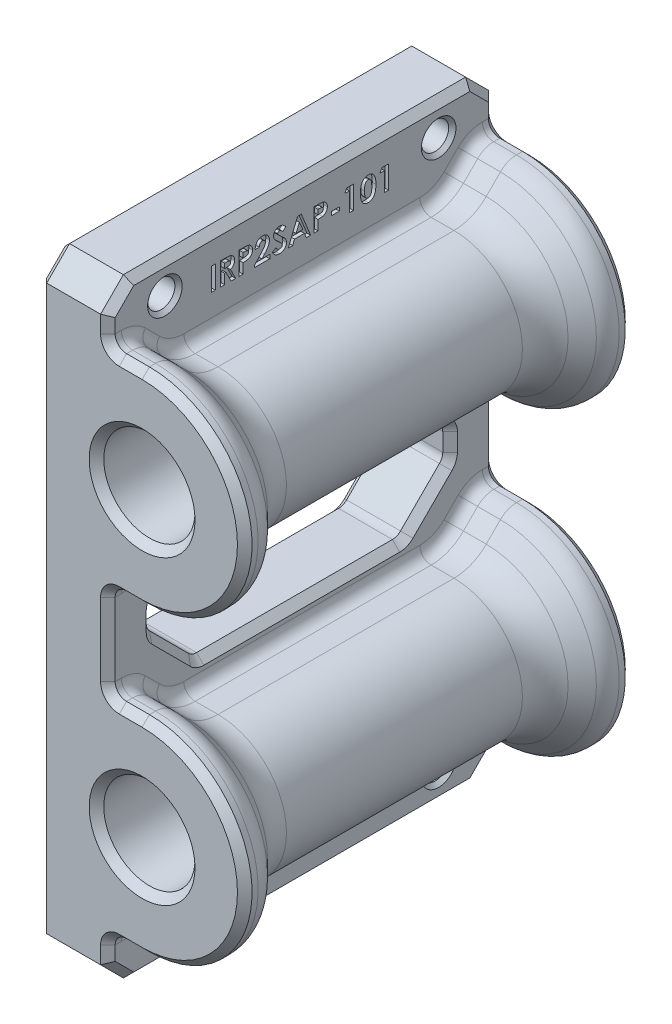
from build123d import *

# Parameters (mm, degrees)
SKETCH1_R             = 6.35
BOSS_EXTRUDE1_DEPTH   = 53.975
CUT_REVOLVE1_ANGLE    = 180
CUT_EXTRUDE3_DEPTH    = 4.7625
FILLET2_R             = 6.35
FILLET3_R             = 3.175
F_6_CLEARANCE_HOLE1_D = 3.7973
CUT_EXTRUDE1_DEPTH    = 10.525
FILLET1_R             = 1.5875
CHAMFER2_SIZE         = 3.175
CHAMFER1_SIZE         = 1.016
CHAMFER3_SIZE         = 0.508
SKETCH7_W             = 0.569871794
SKETCH7_H             = 3.175
SKETCH7_W_2           = 1.099038461
SKETCH7_H_2           = 0.529166666
CUT_EXTRUDE2_DEPTH    = 0.508


with BuildPart() as part:
    # Sketch1 → Boss-Extrude1 (new body)
    with BuildSketch(Plane.XY):
        with BuildLine():
            Line((0, 0), (0, -84.7725))
            Line((0, -84.7725), (14.2875, -84.7725))
            Line((14.2875, -84.7725), (14.2875, -77.62875))
            ThreePointArc((14.2875, -77.62875), (28.575, -63.34125), (14.2875, -49.05375))
            Line((14.2875, -49.05375), (14.2875, -35.71875))
            ThreePointArc((14.2875, -35.71875), (28.575, -21.43125), (14.2875, -7.14375))
            Line((14.2875, -7.14375), (14.2875, 0))
            Line((14.2875, 0), (0, 0))
        make_face()
        with Locations((14.2875, -21.43125)):
            Circle(SKETCH1_R, mode=Mode.SUBTRACT)
        with Locations((14.2875, -63.34125)):
            Circle(SKETCH1_R, mode=Mode.SUBTRACT)
    extrude(amount=BOSS_EXTRUDE1_DEPTH)

    # Sketch8 → Cut-Revolve1 (revolve, cut)
    with BuildSketch(Plane(origin=(14.2875, 0, 0), x_dir=(0, 0, -1), z_dir=(1, 0, 0))):
        Polygon((-46.0375, -30.95625), (-50.8, -35.71875), (-3.175, -35.71875), (-7.9375, -30.95625), align=None)
    cut_revolve1 = revolve(axis=Axis((14.2875, -21.43125, 53.975), (0, 0, 1)), revolution_arc=CUT_REVOLVE1_ANGLE, mode=Mode.SUBTRACT)

    # Mirror1: Cut-Revolve1 across plane
    add(cut_revolve1.mirror(Plane(origin=(0, -42.38625, 0), x_dir=(0, 0, 1), z_dir=(0, -1, 0))), mode=Mode.SUBTRACT)

    # Sketch9 → Cut-Extrude3 (cut)
    with BuildSketch(Plane(origin=(14.2875, 0, 0), x_dir=(0, 0, -1), z_dir=(1, 0, 0))):
        Polygon((0, -7.14375), (0, 0), (-53.975, 0), (-53.975, -7.14375), (-50.8, -7.14375), (-46.0375, -11.90625), (-7.9375, -11.90625), (-3.175, -7.14375), align=None)
        Polygon((0, -49.05375), (0, -35.71875), (-3.175, -35.71875), (-7.9375, -30.95625), (-46.0375, -30.95625), (-50.8, -35.71875), (-53.975, -35.71875), (-53.975, -49.05375), (-50.8, -49.05375), (-46.0375, -53.81625), (-7.9375, -53.81625), (-3.175, -49.05375), align=None)
        Polygon((0, -84.7725), (0, -77.62875), (-3.175, -77.62875), (-7.9375, -72.86625), (-46.0375, -72.86625), (-50.8, -77.62875), (-53.975, -77.62875), (-53.975, -84.7725), align=None)
    extrude(amount=-CUT_EXTRUDE3_DEPTH, mode=Mode.SUBTRACT)

    # Fillet2
    fillet2_edges = [part.edges().sort_by_distance(p)[0] for p in [
        (23.8125, -21.43125, 7.9375),
        (23.8125, -21.43125, 46.0375),
        (23.8125, -63.34125, 7.9375),
        (23.8125, -63.34125, 46.0375),
        (11.90625, -11.90625, 7.9375),
        (11.90625, -11.90625, 46.0375),
        (11.90625, -53.81625, 7.9375),
        (11.90625, -53.81625, 46.0375),
        (11.90625, -30.95625, 46.0375),
        (11.90625, -30.95625, 7.9375),
        (11.90625, -72.86625, 46.0375),
        (11.90625, -72.86625, 7.9375),
    ]]
    fillet(fillet2_edges, radius=FILLET2_R)

    # Fillet3
    fillet3_edges = [part.edges().sort_by_distance(p)[0] for p in [
        (28.575, -21.43125, 3.175),
        (28.575, -21.43125, 50.8),
        (28.575, -63.34125, 50.8),
        (28.575, -63.34125, 3.175),
        (11.90625, -7.14375, 3.175),
        (11.90625, -7.14375, 50.8),
        (11.90625, -49.05375, 3.175),
        (11.90625, -49.05375, 50.8),
        (11.90625, -35.71875, 50.8),
        (11.90625, -35.71875, 3.175),
        (11.90625, -77.62875, 50.8),
        (11.90625, -77.62875, 3.175),
    ]]
    fillet(fillet3_edges, radius=FILLET3_R)

    # #6 Clearance Hole1 (through all)
    with Locations(Plane(origin=(9.525, 0, 0), x_dir=(0, 0, -1), z_dir=(1, 0, 0))):
        with Locations((-46.0375, -4.445), (-7.9375, -4.445), (-46.0375, -80.3275), (-7.9375, -80.3275)):
            Hole(F_6_CLEARANCE_HOLE1_D / 2)

    # Sketch6 → Cut-Extrude1 (cut, through all)
    with BuildSketch(Plane(origin=(9.525, 0, 0), x_dir=(0, 0, -1), z_dir=(1, 0, 0))):
        Polygon((-41.275, -34.13125), (-47.625, -40.48125), (-47.625, -44.29125), (-41.275, -50.64125), (-12.7, -50.64125), (-6.35, -44.29125), (-6.35, -40.48125), (-12.7, -34.13125), align=None)
    extrude(amount=-CUT_EXTRUDE1_DEPTH, mode=Mode.SUBTRACT)

    # Fillet1
    fillet1_edges = [part.edges().sort_by_distance(p)[0] for p in [
        (9.525, -11.90625, 26.9875),
        (9.525, -9.060032015, 48.883717985),
        (9.525, -11.422885031, 45.837283674),
        (9.525, -11.422885031, 8.137716326),
        (9.525, -30.95625, 26.9875),
        (9.525, -33.802467985, 5.091282015),
        (9.525, -50.970032015, 48.883717985),
        (9.525, -53.81625, 26.9875),
        (9.525, -53.332885031, 45.837283674),
        (9.525, -53.332885031, 8.137716326),
        (9.525, -31.439614969, 45.837283674),
        (9.525, -31.439614969, 8.137716326),
        (9.525, -72.86625, 26.9875),
        (9.525, -75.712467985, 5.091282015),
        (9.525, -73.349614969, 45.837283674),
        (9.525, -73.349614969, 8.137716326),
        (9.525, -9.060032015, 5.091282015),
        (9.525, -35.71875, 0.92993597),
        (9.525, -7.14375, 53.04506403),
        (9.525, -33.802467985, 48.883717985),
        (9.525, -77.62875, 0.92993597),
        (9.525, -50.970032015, 5.091282015),
        (9.525, -75.712467985, 48.883717985),
        (9.525, -49.05375, 53.04506403),
        (9.525, -7.385432484, 3.074891837),
        (9.525, -35.477067516, 3.074891837),
        (9.525, -7.385432484, 50.900108163),
        (9.525, -35.477067516, 50.900108163),
        (9.525, -77.387067516, 3.074891837),
        (9.525, -49.295432484, 3.074891837),
        (9.525, -77.387067516, 50.900108163),
        (9.525, -49.295432484, 50.900108163),
        (4.7625, -34.13125, 41.275),
        (4.7625, -34.13125, 12.7),
        (4.7625, -40.48125, 6.35),
        (4.7625, -44.29125, 6.35),
        (4.7625, -50.64125, 12.7),
        (4.7625, -50.64125, 41.275),
        (4.7625, -44.29125, 47.625),
        (4.7625, -40.48125, 47.625),
        (9.525, -7.14375, 0.92993597),
        (9.525, -49.05375, 0.92993597),
        (9.525, -35.71875, 53.04506403),
        (9.525, -77.62875, 53.04506403),
    ]]
    fillet(fillet1_edges, radius=FILLET1_R)

    # Chamfer2
    chamfer2_edges = [part.edges().sort_by_distance(p)[0] for p in [
        (4.7625, -84.7725, 0),
        (4.7625, -84.7725, 53.975),
        (4.7625, 0, 0),
        (4.7625, 0, 53.975),
    ]]
    chamfer(chamfer2_edges, length=CHAMFER2_SIZE)

    # Chamfer1
    chamfer1_edges = [part.edges().sort_by_distance(p)[0] for p in [
        (28.575, -63.34125, 53.975),
        (7.9375, -21.43125, 0),
        (7.9375, -21.43125, 53.975),
        (7.9375, -63.34125, 0),
        (7.9375, -63.34125, 53.975),
        (28.575, -21.43125, 53.975),
        (12.7, -35.71875, 53.975),
        (9.525, -34.13125, 26.9875),
        (9.525, -37.30625, 9.525),
        (9.525, -42.38625, 6.35),
        (9.525, -47.46625, 9.525),
        (9.525, -50.64125, 26.9875),
        (9.525, -47.46625, 44.45),
        (9.525, -42.38625, 47.625),
        (9.525, -37.30625, 44.45),
        (9.525, -42.38625, 53.975),
        (9.525, -42.38625, 0),
        (12.7, -35.71875, 0),
        (12.7, -7.14375, 0),
        (9.525, -4.365625, 53.975),
        (12.7, -7.14375, 53.975),
        (12.7, -49.05375, 0),
        (12.7, -49.05375, 53.975),
        (12.7, -77.62875, 53.975),
        (9.525, -80.406875, 0),
        (12.7, -77.62875, 0),
        (0, -47.46625, 9.525),
        (0, -50.64125, 26.9875),
        (0, -47.46625, 44.45),
        (0, -42.38625, 47.625),
        (0, -37.30625, 44.45),
        (0, -34.13125, 26.9875),
        (0, -42.38625, 6.35),
        (0, -37.30625, 9.525),
        (9.989967985, -36.183717985, 53.975),
        (9.989967985, -36.183717985, 0),
        (9.989967985, -6.678782015, 0),
        (9.989967985, -6.678782015, 53.975),
        (9.989967985, -48.588782015, 0),
        (9.989967985, -48.588782015, 53.975),
        (9.989967985, -78.093717985, 53.975),
        (9.989967985, -78.093717985, 0),
        (9.525, -50.520408758, 12.750054081),
        (0, -50.520408758, 12.750054081),
        (9.525, -50.520408758, 41.224945919),
        (0, -50.520408758, 41.224945919),
        (9.525, -44.241195919, 47.504158758),
        (0, -44.241195919, 47.504158758),
        (9.525, -40.531304081, 47.504158758),
        (0, -40.531304081, 47.504158758),
        (9.525, -34.252091242, 41.224945919),
        (0, -34.252091242, 41.224945919),
        (9.525, -44.241195919, 6.470841242),
        (0, -44.241195919, 6.470841242),
        (9.525, -40.531304081, 6.470841242),
        (0, -40.531304081, 6.470841242),
        (9.525, -34.252091242, 12.750054081),
        (0, -34.252091242, 12.750054081),
        (9.525, -84.7725, 26.9875),
        (0, -84.7725, 26.9875),
        (9.525, -80.406875, 53.975),
        (9.525, -83.185, 52.3875),
        (9.525, -83.185, 1.5875),
        (9.525, -4.365625, 0),
        (0, -42.38625, 0),
        (0, -42.38625, 53.975),
        (0, 0, 26.9875),
        (0, -1.5875, 52.3875),
        (0, -1.5875, 1.5875),
        (0, -83.185, 52.3875),
        (0, -83.185, 1.5875),
        (9.525, 0, 26.9875),
        (9.525, -1.5875, 52.3875),
        (9.525, -1.5875, 1.5875),
        (28.575, -21.43125, 0),
        (28.575, -63.34125, 0),
    ]]
    chamfer(chamfer1_edges, length=CHAMFER1_SIZE)

    # Chamfer3
    chamfer3_edges = [part.edges().sort_by_distance(p)[0] for p in [
        (9.525, -80.3275, 6.03885),
        (0, -80.3275, 6.03885),
        (9.525, -80.3275, 44.13885),
        (0, -80.3275, 44.13885),
        (9.525, -4.445, 6.03885),
        (0, -4.445, 6.03885),
        (9.525, -4.445, 44.13885),
        (0, -4.445, 44.13885),
    ]]
    chamfer(chamfer3_edges, length=CHAMFER3_SIZE)

    # Sketch7 → Cut-Extrude2 (cut)
    with BuildSketch(Plane(origin=(9.525, 0, 0), x_dir=(0, 0, -1), z_dir=(1, 0, 0))):
        with Locations((-39.300801282, -5.667375)):
            Rectangle(SKETCH7_W, SKETCH7_H)
        with BuildLine():
            Line((-38.283173077, -4.079875), (-37.619170673, -4.079875))
            add(Edge.make_bspline(
                [(-37.619170673, -4.079875), (-37.575280316, -4.080030786), (-37.490866797, -4.080330405), (-37.369147113, -4.085057608), (-37.257330843, -4.091635899), (-37.155252435, -4.101674545), (-37.062955559, -4.114984576), (-36.980347711, -4.130674901), (-36.907431307, -4.14855739), (-36.843591397, -4.170840381), (-36.785979034, -4.195975258), (-36.732276303, -4.224855693), (-36.681298441, -4.257160092), (-36.633386179, -4.293738472), (-36.58812315, -4.333932798), (-36.545423961, -4.377783527), (-36.505891992, -4.425662498), (-36.469772026, -4.477267174), (-36.436851584, -4.53155411), (-36.407756819, -4.588597843), (-36.384096907, -4.648438041), (-36.363190839, -4.710209886), (-36.348132875, -4.774796417), (-36.337660281, -4.841568875), (-36.329992658, -4.910762304), (-36.329551806, -4.957769247), (-36.329326923, -4.981747997)],
                knots=[0, 0, 0, 0, 0.000131662, 0.000253223, 0.00036538, 0.000467651, 0.000560835, 0.000645033, 0.000719848, 0.000785822, 0.000847624, 0.000908233, 0.000968574, 0.001028488, 0.00108886, 0.00115003, 0.00121192, 0.001274915, 0.001338834, 0.001402263, 0.001466749, 0.001531714, 0.00159774, 0.001665392, 0.001734437, 0.001806332, 0.001806332, 0.001806332, 0.001806332], degree=3))
            add(Edge.make_bspline(
                [(-36.329326923, -4.981747997), (-36.329911089, -5.006776303), (-36.331056531, -5.055852249), (-36.337226507, -5.127940812), (-36.348503286, -5.196910106), (-36.365583607, -5.262558199), (-36.385215218, -5.325702157), (-36.411320224, -5.385176934), (-36.440782304, -5.441847505), (-36.475773556, -5.494912244), (-36.514174745, -5.545549824), (-36.55883452, -5.591820132), (-36.606859614, -5.636210022), (-36.660949691, -5.675939061), (-36.718720412, -5.713693583), (-36.78131962, -5.747909235), (-36.84833877, -5.779446119), (-36.895456552, -5.797033263), (-36.919551282, -5.806026843)],
                knots=[0, 0, 0, 0, 7.5093e-05, 0.000147244, 0.000216881, 0.000284446, 0.00035062, 0.000415008, 0.000479022, 0.000542001, 0.000605481, 0.000669369, 0.000734656, 0.000801438, 0.000870416, 0.000941581, 0.001015277, 0.001092403, 0.001092403, 0.001092403, 0.001092403], degree=3))
            Line((-36.919551282, -5.806026843), (-36.186858974, -7.254875))
            Line((-36.186858974, -7.254875), (-36.820332532, -7.254875))
            Line((-36.820332532, -7.254875), (-37.519951923, -5.870900641))
            Line((-37.519951923, -5.870900641), (-37.713301282, -5.870900641))
            Line((-37.713301282, -5.870900641), (-37.713301282, -7.254875))
            Line((-37.713301282, -7.254875), (-38.283173077, -7.254875))
            Line((-38.283173077, -7.254875), (-38.283173077, -4.079875))
        make_face()
        with BuildLine():
            Line((-37.713301282, -5.301028846), (-37.49133113, -5.301028846))
            add(Edge.make_bspline(
                [(-37.49133113, -5.301028846), (-37.464193434, -5.300723203), (-37.412230576, -5.300137963), (-37.337501163, -5.297423374), (-37.269629034, -5.290882557), (-37.208322722, -5.282618479), (-37.153273742, -5.273076407), (-37.104973109, -5.25940204), (-37.062676585, -5.244749608), (-37.026885385, -5.226540437), (-36.996306206, -5.20583266), (-36.969903042, -5.182308111), (-36.94806384, -5.15508144), (-36.930089063, -5.124892552), (-36.916106641, -5.091474433), (-36.905900543, -5.055193938), (-36.900196844, -5.015637786), (-36.899540614, -4.988338655), (-36.899198718, -4.974115785)],
                knots=[0, 0, 0, 0, 8.142e-05, 0.000155902, 0.000224253, 0.000285868, 0.000341504, 0.000391652, 0.000436319, 0.000475572, 0.000511736, 0.000546861, 0.000581229, 0.000616025, 0.000651936, 0.00068959, 0.000728807, 0.000771463, 0.000771463, 0.000771463, 0.000771463], degree=3))
            add(Edge.make_bspline(
                [(-36.899198718, -4.974115785), (-36.899845104, -4.957289092), (-36.901114811, -4.92423617), (-36.913714243, -4.876651553), (-36.933769817, -4.832608734), (-36.961260515, -4.79230671), (-36.995881476, -4.756975173), (-37.035611761, -4.725830142), (-37.081308844, -4.701202982), (-37.123620904, -4.68495917), (-37.162114988, -4.675240329), (-37.196854685, -4.667997935), (-37.237083463, -4.662865042), (-37.282831693, -4.657420696), (-37.333982761, -4.653890313), (-37.390815471, -4.651313837), (-37.4531666, -4.650259674), (-37.496631258, -4.649922677), (-37.519315905, -4.649746795)],
                knots=[0, 0, 0, 0, 5.039e-05, 9.8982e-05, 0.000146513, 0.000195026, 0.000244505, 0.000294375, 0.000345896, 0.000399642, 0.000429878, 0.000464928, 0.000506034, 0.000551477, 0.000603136, 0.000659798, 0.000722141, 0.000790198, 0.000790198, 0.000790198, 0.000790198], degree=3))
            Line((-37.519315905, -4.649746795), (-37.713301282, -4.649746795))
            Line((-37.713301282, -4.649746795), (-37.713301282, -5.301028846))
        make_face(mode=Mode.SUBTRACT)
        with BuildLine():
            Line((-35.71875, -4.079875), (-35.082732372, -4.079875))
            add(Edge.make_bspline(
                [(-35.082732372, -4.079875), (-35.041175805, -4.080061016), (-34.961004477, -4.08041988), (-34.845390826, -4.084771582), (-34.738731572, -4.092570098), (-34.64105122, -4.102207831), (-34.552389934, -4.115719557), (-34.472636684, -4.131209692), (-34.401774917, -4.150081186), (-34.339005564, -4.172481387), (-34.282672096, -4.19889035), (-34.229362467, -4.22701778), (-34.180281479, -4.260586875), (-34.132951867, -4.295979702), (-34.090079546, -4.336577323), (-34.048989885, -4.379677907), (-34.011423142, -4.426990789), (-33.977205248, -4.477943259), (-33.946164345, -4.531593932), (-33.919044935, -4.588038721), (-33.897047189, -4.647366943), (-33.878593815, -4.709194813), (-33.863771886, -4.773519635), (-33.853905938, -4.840737013), (-33.847204489, -4.91037761), (-33.846613179, -4.957775045), (-33.846314103, -4.981747997)],
                knots=[0, 0, 0, 0, 0.000124666, 0.000240507, 0.000346996, 0.000445469, 0.000534879, 0.000615956, 0.000689087, 0.000754674, 0.000815576, 0.000875625, 0.000935248, 0.000993765, 0.001052722, 0.001112114, 0.001172308, 0.001233696, 0.001296097, 0.001358115, 0.001421314, 0.001485706, 0.001551589, 0.001619141, 0.001689392, 0.001761287, 0.001761287, 0.001761287, 0.001761287], degree=3))
            add(Edge.make_bspline(
                [(-33.846314103, -4.981747997), (-33.846746829, -5.008268703), (-33.847597189, -5.06038515), (-33.855933456, -5.136781467), (-33.870174435, -5.209618439), (-33.888786649, -5.279510312), (-33.914740059, -5.345307211), (-33.94439061, -5.408579069), (-33.980870194, -5.467551938), (-34.022553949, -5.522963498), (-34.068077366, -5.57526427), (-34.118521168, -5.622944169), (-34.172923874, -5.666328227), (-34.230970567, -5.705871112), (-34.292879171, -5.741493058), (-34.358605016, -5.773527626), (-34.428596916, -5.800950251), (-34.477337169, -5.815292062), (-34.502048277, -5.822563301)],
                knots=[0, 0, 0, 0, 7.9543e-05, 0.000156312, 0.000230155, 0.000302059, 0.000372929, 0.000442056, 0.000511431, 0.000580503, 0.000649908, 0.00071919, 0.000788422, 0.000858457, 0.000929693, 0.001002514, 0.001077631, 0.001154881, 0.001154881, 0.001154881, 0.001154881], degree=3))
            add(Edge.make_bspline(
                [(-34.502048277, -5.822563301), (-34.518324435, -5.826612836), (-34.553583833, -5.835385431), (-34.611928453, -5.844291817), (-34.679164502, -5.852480692), (-34.755509397, -5.859518038), (-34.841007154, -5.864301794), (-34.935574988, -5.868037694), (-35.039255756, -5.870754079), (-35.111351262, -5.870850469), (-35.148878205, -5.870900641)],
                knots=[0, 0, 0, 0, 5.0294e-05, 0.000108952, 0.000176875, 0.000253517, 0.000338896, 0.000433739, 0.000537441, 0.000650018, 0.000650018, 0.000650018, 0.000650018], degree=3))
            Line((-35.148878205, -5.870900641), (-35.148878205, -7.254875))
            Line((-35.148878205, -7.254875), (-35.71875, -7.254875))
            Line((-35.71875, -7.254875), (-35.71875, -4.079875))
        make_face()
        with BuildLine():
            Line((-35.148878205, -5.301028846), (-34.947260617, -5.301028846))
            add(Edge.make_bspline(
                [(-34.947260617, -5.301028846), (-34.910573114, -5.300796219), (-34.843067563, -5.300368181), (-34.750878818, -5.294178509), (-34.67679417, -5.284725629), (-34.618265922, -5.271168013), (-34.572052327, -5.250592536), (-34.532195995, -5.226790583), (-34.498010201, -5.196693667), (-34.468410335, -5.162302791), (-34.444746134, -5.122785951), (-34.428336243, -5.078786601), (-34.417676701, -5.031229216), (-34.416692193, -4.998132423), (-34.416185897, -4.981111979)],
                knots=[0, 0, 0, 0, 0.000110048, 0.000202489, 0.000276966, 0.000334041, 0.000381895, 0.000428145, 0.00047278, 0.000517897, 0.000563818, 0.000610121, 0.000658274, 0.000709254, 0.000709254, 0.000709254, 0.000709254], degree=3))
            add(Edge.make_bspline(
                [(-34.416185897, -4.981111979), (-34.416686985, -4.966241439), (-34.417659215, -4.937389015), (-34.424801485, -4.895747812), (-34.436184208, -4.85692962), (-34.452677337, -4.821339844), (-34.473999046, -4.789038957), (-34.499994525, -4.760039684), (-34.5303302, -4.73372098), (-34.553751114, -4.719790088), (-34.56565004, -4.71271254)],
                knots=[0, 0, 0, 0, 4.4594e-05, 8.6523e-05, 0.000126364, 0.000165633, 0.000203735, 0.000242029, 0.000282179, 0.000323642, 0.000323642, 0.000323642, 0.000323642], degree=3))
            add(Edge.make_bspline(
                [(-34.56565004, -4.71271254), (-34.575729117, -4.707615262), (-34.597068588, -4.696823279), (-34.633411777, -4.68427681), (-34.675351262, -4.673692482), (-34.723170181, -4.664907591), (-34.776677772, -4.658089604), (-34.835864488, -4.652875549), (-34.900817427, -4.650778775), (-34.94598831, -4.650100276), (-34.969521234, -4.649746795)],
                knots=[0, 0, 0, 0, 3.3853e-05, 7.1673e-05, 0.00011502, 0.000163546, 0.000217427, 0.000276795, 0.000341719, 0.000412328, 0.000412328, 0.000412328, 0.000412328], degree=3))
            Line((-34.969521234, -4.649746795), (-35.148878205, -4.649746795))
            Line((-35.148878205, -4.649746795), (-35.148878205, -5.301028846))
        make_face(mode=Mode.SUBTRACT)
        with BuildLine():
            Line((-32.910096154, -5.138208333), (-33.479967949, -5.138208333))
            add(Edge.make_bspline(
                [(-33.479967949, -5.138208333), (-33.47750676, -5.095100547), (-33.472697745, -5.01087052), (-33.453568697, -4.88852371), (-33.42793643, -4.772919428), (-33.393726767, -4.66446207), (-33.350740087, -4.563191048), (-33.300082548, -4.468761121), (-33.240459965, -4.381669467), (-33.173141302, -4.302336089), (-33.099269446, -4.231165384), (-33.020378049, -4.168060966), (-32.93526036, -4.115988788), (-32.845471549, -4.073138206), (-32.751026906, -4.038902583), (-32.651032835, -4.016013298), (-32.54635514, -4.00051245), (-32.474694781, -3.999156064), (-32.438171074, -3.998464744)],
                knots=[0, 0, 0, 0, 0.000129464, 0.000252964, 0.000371, 0.000484446, 0.000593599, 0.000700601, 0.00080539, 0.000909629, 0.001012184, 0.001112707, 0.001212082, 0.001310796, 0.001410781, 0.001512752, 0.001618079, 0.001727565, 0.001727565, 0.001727565, 0.001727565], degree=3))
            add(Edge.make_bspline(
                [(-32.438171074, -3.998464744), (-32.393338741, -3.999863631), (-32.30581552, -4.002594586), (-32.178637338, -4.02589054), (-32.059866822, -4.064856624), (-31.949590306, -4.119302519), (-31.848746593, -4.188470321), (-31.757352407, -4.270941605), (-31.678171653, -4.368446662), (-31.610702301, -4.476928465), (-31.554643334, -4.591795426), (-31.515359545, -4.710572628), (-31.489538733, -4.830108205), (-31.486784784, -4.910597412), (-31.485416667, -4.950583133)],
                knots=[0, 0, 0, 0, 0.000134417, 0.000262413, 0.000386307, 0.000508331, 0.000630055, 0.000752073, 0.000876344, 0.001005517, 0.001134666, 0.001258761, 0.001380127, 0.001499942, 0.001499942, 0.001499942, 0.001499942], degree=3))
            add(Edge.make_bspline(
                [(-31.485416667, -4.950583133), (-31.485949339, -4.974769323), (-31.487021477, -5.02345015), (-31.494476197, -5.097116188), (-31.505659749, -5.172153661), (-31.522521819, -5.248498231), (-31.543550204, -5.326171298), (-31.569060674, -5.405405311), (-31.59964497, -5.485751042), (-31.634792702, -5.56811277), (-31.676724036, -5.652757889), (-31.725547245, -5.740955263), (-31.782558209, -5.832626655), (-31.847068307, -5.92828967), (-31.919390848, -6.027793434), (-31.999878889, -6.130838211), (-32.087605395, -6.237787096), (-32.149867364, -6.309276423), (-32.18185597, -6.346005809)],
                knots=[0, 0, 0, 0, 7.2551e-05, 0.000146026, 0.000221945, 0.000300038, 0.00038042, 0.000463288, 0.000549639, 0.000638247, 0.000731828, 0.000832893, 0.00094056, 0.001055574, 0.001178976, 0.001309507, 0.001447785, 0.001593897, 0.001593897, 0.001593897, 0.001593897], degree=3))
            Line((-32.18185597, -6.346005809), (-32.513221154, -6.725708333))
            Line((-32.513221154, -6.725708333), (-31.444711538, -6.725708333))
            Line((-31.444711538, -6.725708333), (-31.444711538, -7.254875))
            Line((-31.444711538, -7.254875), (-33.561378205, -7.254875))
            Line((-33.561378205, -7.254875), (-33.561378205, -6.966122997))
            Line((-33.561378205, -6.966122997), (-32.621344151, -5.965667268))
            add(Edge.make_bspline(
                [(-32.621344151, -5.965667268), (-32.594127749, -5.936483663), (-32.54141765, -5.879963676), (-32.466416612, -5.796958063), (-32.398547298, -5.718187716), (-32.339217032, -5.642813892), (-32.285312241, -5.573281411), (-32.239236533, -5.507494476), (-32.200568352, -5.446047826), (-32.158588557, -5.371953897), (-32.118721552, -5.283583702), (-32.082141161, -5.181777613), (-32.059842882, -5.08447444), (-32.056765014, -5.0210696), (-32.055288462, -4.990652244)],
                knots=[0, 0, 0, 0, 0.000119713, 0.000231849, 0.000335604, 0.000431556, 0.000519584, 0.000599513, 0.000672392, 0.000737318, 0.000854858, 0.000962674, 0.0010616, 0.00115282, 0.00115282, 0.00115282, 0.00115282], degree=3))
            add(Edge.make_bspline(
                [(-32.055288462, -4.990652244), (-32.056392444, -4.961225798), (-32.058531588, -4.904207342), (-32.082039046, -4.823098891), (-32.118457616, -4.749663469), (-32.169776523, -4.686095409), (-32.231939793, -4.633857318), (-32.303775291, -4.595004094), (-32.384697346, -4.572585962), (-32.441425248, -4.569780012), (-32.470607973, -4.568336538)],
                knots=[0, 0, 0, 0, 8.8049e-05, 0.000170609, 0.000251105, 0.000332555, 0.000413826, 0.000493216, 0.000575776, 0.000663244, 0.000663244, 0.000663244, 0.000663244], degree=3))
            add(Edge.make_bspline(
                [(-32.470607973, -4.568336538), (-32.48568414, -4.568869775), (-32.515363996, -4.569919537), (-32.558991065, -4.576907517), (-32.600505356, -4.589223102), (-32.640368945, -4.605724253), (-32.678156398, -4.627596647), (-32.713772403, -4.654557857), (-32.74759222, -4.685922738), (-32.779460737, -4.721593216), (-32.808465248, -4.76140148), (-32.834226949, -4.804983963), (-32.855527587, -4.852313611), (-32.874281442, -4.902765602), (-32.888745313, -4.95688183), (-32.899276805, -5.014338417), (-32.907283196, -5.075041887), (-32.909141444, -5.116769815), (-32.910096154, -5.138208333)],
                knots=[0, 0, 0, 0, 4.5229e-05, 8.904e-05, 0.000132111, 0.000174871, 0.000218181, 0.000262703, 0.000308611, 0.000356359, 0.000405972, 0.000456149, 0.000507944, 0.000561468, 0.000617474, 0.000675728, 0.000736629, 0.00080098, 0.00080098, 0.00080098, 0.00080098], degree=3))
        make_face()
        with BuildLine():
            Line((-29.205929487, -4.504098758), (-29.632061298, -4.893977564))
            add(Edge.make_bspline(
                [(-29.632061298, -4.893977564), (-29.650314958, -4.86822888), (-29.685359438, -4.818794996), (-29.742162887, -4.752601861), (-29.798709838, -4.696134191), (-29.855524166, -4.649627881), (-29.913109451, -4.613365493), (-29.971365733, -4.587691321), (-30.029962742, -4.571370007), (-30.069330886, -4.56933761), (-30.088721955, -4.568336538)],
                knots=[0, 0, 0, 0, 9.4645e-05, 0.000181705, 0.000261309, 0.000334118, 0.000401536, 0.000464758, 0.000524615, 0.000582716, 0.000582716, 0.000582716, 0.000582716], degree=3))
            add(Edge.make_bspline(
                [(-30.088721955, -4.568336538), (-30.106809388, -4.568970863), (-30.141731469, -4.570195578), (-30.191515487, -4.582369153), (-30.235714446, -4.603378956), (-30.274285212, -4.63085104), (-30.304838949, -4.663948533), (-30.329233739, -4.698659293), (-30.342970055, -4.736972121), (-30.344778025, -4.763286918), (-30.345673077, -4.776314303)],
                knots=[0, 0, 0, 0, 5.4196e-05, 0.000104638, 0.000152437, 0.000200274, 0.000245717, 0.000286994, 0.000326825, 0.000365877, 0.000365877, 0.000365877, 0.000365877], degree=3))
            add(Edge.make_bspline(
                [(-30.345673077, -4.776314303), (-30.345112193, -4.789529549), (-30.343982651, -4.816143217), (-30.333072812, -4.855148863), (-30.31662857, -4.89326192), (-30.300915426, -4.916463151), (-30.292883614, -4.928322516)],
                knots=[0, 0, 0, 0, 3.9561e-05, 7.9671e-05, 0.000120678, 0.000163556, 0.000163556, 0.000163556, 0.000163556], degree=3))
            add(Edge.make_bspline(
                [(-30.292883614, -4.928322516), (-30.285581828, -4.937540676), (-30.268774082, -4.958759664), (-30.236725152, -4.992367234), (-30.196478426, -5.033539448), (-30.146485127, -5.080860515), (-30.088820613, -5.136032286), (-30.02081206, -5.196885937), (-29.94441705, -5.265306035), (-29.890117247, -5.312951314), (-29.861663662, -5.337917869)],
                knots=[0, 0, 0, 0, 3.5263e-05, 8.1171e-05, 0.000139188, 0.000208011, 0.000287645, 0.000378602, 0.000481757, 0.000595317, 0.000595317, 0.000595317, 0.000595317], degree=3))
            add(Edge.make_bspline(
                [(-29.861663662, -5.337917869), (-29.834955879, -5.361032108), (-29.784270056, -5.404898131), (-29.712154194, -5.467158908), (-29.648776363, -5.523173411), (-29.593213292, -5.572100982), (-29.546307262, -5.614454984), (-29.50786108, -5.650437867), (-29.477405192, -5.679349112), (-29.460092803, -5.696811522), (-29.452704327, -5.704264022)],
                knots=[0, 0, 0, 0, 0.000105963, 0.000201096, 0.000285818, 0.000359711, 0.000423202, 0.000475401, 0.000517686, 0.000549167, 0.000549167, 0.000549167, 0.000549167], degree=3))
            add(Edge.make_bspline(
                [(-29.452704327, -5.704264022), (-29.42467399, -5.734598851), (-29.370789837, -5.792913044), (-29.300759435, -5.883281703), (-29.243122148, -5.971499942), (-29.198532851, -6.059227728), (-29.16485722, -6.1477308), (-29.141115454, -6.23917969), (-29.126896352, -6.334529982), (-29.1253177, -6.399594916), (-29.124519231, -6.432504207)],
                knots=[0, 0, 0, 0, 0.00012386, 0.000238103, 0.000342543, 0.000439538, 0.000532738, 0.000626068, 0.000722491, 0.000821174, 0.000821174, 0.000821174, 0.000821174], degree=3))
            add(Edge.make_bspline(
                [(-29.124519231, -6.432504207), (-29.12508756, -6.464570275), (-29.126202645, -6.527485094), (-29.139860286, -6.61955156), (-29.159335281, -6.707663163), (-29.18944704, -6.790861126), (-29.226147073, -6.870511116), (-29.272155865, -6.945372441), (-29.326186883, -7.016202728), (-29.388114725, -7.081735799), (-29.456614272, -7.141202518), (-29.530086547, -7.194141196), (-29.609249998, -7.237848818), (-29.693428264, -7.273838927), (-29.782576288, -7.30155899), (-29.876587868, -7.3220467), (-29.975606799, -7.334343101), (-30.043317372, -7.335628544), (-30.077909655, -7.336285256)],
                knots=[0, 0, 0, 0, 9.6114e-05, 0.00018858, 0.000278679, 0.000366385, 0.000453452, 0.00054137, 0.000629398, 0.000720284, 0.000811348, 0.00090118, 0.000991434, 0.001082046, 0.001175382, 0.001271066, 0.001370387, 0.001474128, 0.001474128, 0.001474128, 0.001474128], degree=3))
            add(Edge.make_bspline(
                [(-30.077909655, -7.336285256), (-30.105064304, -7.335803515), (-30.15884608, -7.33484939), (-30.238112288, -7.327059758), (-30.314652772, -7.314488119), (-30.388381316, -7.296469206), (-30.459630081, -7.273636799), (-30.528401993, -7.245747888), (-30.594222295, -7.212370206), (-30.657589017, -7.174190131), (-30.718194117, -7.129858035), (-30.776803923, -7.080280272), (-30.832836267, -7.024694316), (-30.88656026, -6.963231623), (-30.937632162, -6.895718147), (-30.98772374, -6.823094139), (-31.034608772, -6.744011794), (-31.063571742, -6.688534889), (-31.078365385, -6.660198518)],
                knots=[0, 0, 0, 0, 8.145e-05, 0.000161318, 0.000238693, 0.000313971, 0.000388795, 0.000462967, 0.000536351, 0.000609979, 0.000684656, 0.000761369, 0.000840074, 0.000921205, 0.001006053, 0.001093907, 0.001185749, 0.001281638, 0.001281638, 0.001281638, 0.001281638], degree=3))
            Line((-31.078365385, -6.660198518), (-30.577183494, -6.359362179))
            add(Edge.make_bspline(
                [(-30.577183494, -6.359362179), (-30.558678858, -6.391527663), (-30.523203891, -6.453191645), (-30.463088242, -6.53604502), (-30.401502829, -6.606995221), (-30.337023851, -6.664788198), (-30.27043535, -6.710196719), (-30.201415688, -6.742648798), (-30.129916371, -6.762736598), (-30.081214285, -6.765189782), (-30.056921074, -6.766413462)],
                knots=[0, 0, 0, 0, 0.000111258, 0.00021329, 0.000306568, 0.00039261, 0.000472343, 0.00054746, 0.000620591, 0.000693376, 0.000693376, 0.000693376, 0.000693376], degree=3))
            add(Edge.make_bspline(
                [(-30.056921074, -6.766413462), (-30.0322114, -6.765414139), (-29.984271033, -6.763475307), (-29.915842294, -6.745566904), (-29.853104235, -6.717449396), (-29.798873921, -6.677329591), (-29.752955109, -6.631025238), (-29.719064391, -6.579509527), (-29.697774013, -6.523770773), (-29.695523104, -6.485050967), (-29.694391026, -6.465577123)],
                knots=[0, 0, 0, 0, 7.4e-05, 0.00014357, 0.000210736, 0.000279054, 0.000344721, 0.000405406, 0.000462951, 0.000521177, 0.000521177, 0.000521177, 0.000521177], degree=3))
            add(Edge.make_bspline(
                [(-29.694391026, -6.465577123), (-29.695436454, -6.447459881), (-29.69756014, -6.410656437), (-29.713202563, -6.355935635), (-29.737656442, -6.301239718), (-29.766587104, -6.256376648), (-29.796027676, -6.218814015), (-29.824179502, -6.186267693), (-29.85846098, -6.150309704), (-29.898785187, -6.110894818), (-29.944619333, -6.067676053), (-29.99600203, -6.020657644), (-30.053521663, -5.970253764), (-30.094176653, -5.93591914), (-30.115434696, -5.917965946)],
                knots=[0, 0, 0, 0, 5.43e-05, 0.000110306, 0.000169524, 0.000233573, 0.000269831, 0.000312672, 0.00036261, 0.000418829, 0.000481817, 0.000551596, 0.000627762, 0.000711235, 0.000711235, 0.000711235, 0.000711235], degree=3))
            add(Edge.make_bspline(
                [(-30.115434696, -5.917965946), (-30.155847081, -5.883773192), (-30.233410681, -5.818146949), (-30.343017888, -5.721219054), (-30.441783795, -5.630631054), (-30.528855355, -5.545263085), (-30.605341994, -5.466691694), (-30.67072571, -5.394278695), (-30.724288234, -5.32746552), (-30.780651241, -5.248329786), (-30.834207366, -5.151897456), (-30.880495057, -5.035878184), (-30.910524557, -4.919873633), (-30.913888945, -4.841994567), (-30.915544872, -4.803663061)],
                knots=[0, 0, 0, 0, 0.000158806, 0.000304796, 0.000438925, 0.00056081, 0.00067056, 0.000767852, 0.000853374, 0.000927311, 0.00105914, 0.001183033, 0.001301505, 0.001416334, 0.001416334, 0.001416334, 0.001416334], degree=3))
            add(Edge.make_bspline(
                [(-30.915544872, -4.803663061), (-30.914856174, -4.776480414), (-30.913499365, -4.72292768), (-30.901396422, -4.644186188), (-30.883308112, -4.568207264), (-30.857038693, -4.495268114), (-30.822944159, -4.425460097), (-30.781537672, -4.358441474), (-30.732176267, -4.294829069), (-30.676549296, -4.234665052), (-30.615262616, -4.179681988), (-30.549770011, -4.131153924), (-30.480442173, -4.090166416), (-30.407703216, -4.056164301), (-30.331102407, -4.030137843), (-30.251204059, -4.011688992), (-30.167893574, -4.000716204), (-30.111227581, -3.99922458), (-30.082361779, -3.998464744)],
                knots=[0, 0, 0, 0, 8.15e-05, 0.000160563, 0.000238464, 0.000315517, 0.000392604, 0.000471146, 0.000551418, 0.000633779, 0.000716652, 0.000798065, 0.00087791, 0.000957869, 0.001038522, 0.001120136, 0.001203522, 0.001290105, 0.001290105, 0.001290105, 0.001290105], degree=3))
            add(Edge.make_bspline(
                [(-30.082361779, -3.998464744), (-30.044953128, -3.999833232), (-29.970431118, -4.002559406), (-29.860248176, -4.023877195), (-29.752626085, -4.057401664), (-29.665902187, -4.097845247), (-29.5968976, -4.137022966), (-29.54401203, -4.173092874), (-29.490198116, -4.214412892), (-29.435021883, -4.261113231), (-29.379508589, -4.314073786), (-29.322079726, -4.37203379), (-29.263517834, -4.435494152), (-29.225461889, -4.480829941), (-29.205929487, -4.504098758)],
                knots=[0, 0, 0, 0, 0.000112158, 0.00022343, 0.000335472, 0.00044959, 0.000509703, 0.000573385, 0.000641441, 0.000713187, 0.000790125, 0.000871527, 0.000957951, 0.001049081, 0.001049081, 0.001049081, 0.001049081], degree=3))
        make_face()
        Polygon((-27.577088341, -4.079875), (-27.048557692, -4.079875), (-25.766346154, -7.254875), (-26.375015024, -7.254875), (-26.621789864, -6.603592949), (-28.005128205, -6.603592949), (-28.251903045, -7.254875), (-28.859935897, -7.254875), align=None)
        Polygon((-27.313141026, -4.931502604), (-27.788882212, -6.033721154), (-26.83739984, -6.033721154), align=None, mode=Mode.SUBTRACT)
        with BuildLine():
            Line((-25.298237179, -4.079875), (-24.662219551, -4.079875))
            add(Edge.make_bspline(
                [(-24.662219551, -4.079875), (-24.620662985, -4.080061016), (-24.540491657, -4.08041988), (-24.424878006, -4.084771582), (-24.318218752, -4.092570098), (-24.2205384, -4.102207831), (-24.131877114, -4.115719557), (-24.052123863, -4.131209692), (-23.981262097, -4.150081186), (-23.918492743, -4.172481387), (-23.862159276, -4.19889035), (-23.808849646, -4.22701778), (-23.759768658, -4.260586875), (-23.712439046, -4.295979702), (-23.669566726, -4.336577323), (-23.628477064, -4.379677907), (-23.590910322, -4.426990789), (-23.556692427, -4.477943259), (-23.525651524, -4.531593932), (-23.498532115, -4.588038721), (-23.476534369, -4.647366943), (-23.458080995, -4.709194813), (-23.443259065, -4.773519635), (-23.433393117, -4.840737013), (-23.426691669, -4.91037761), (-23.426100358, -4.957775045), (-23.425801282, -4.981747997)],
                knots=[0, 0, 0, 0, 0.000124666, 0.000240507, 0.000346996, 0.000445469, 0.000534879, 0.000615956, 0.000689087, 0.000754674, 0.000815576, 0.000875625, 0.000935248, 0.000993765, 0.001052722, 0.001112114, 0.001172308, 0.001233696, 0.001296097, 0.001358115, 0.001421314, 0.001485706, 0.001551589, 0.001619141, 0.001689392, 0.001761287, 0.001761287, 0.001761287, 0.001761287], degree=3))
            add(Edge.make_bspline(
                [(-23.425801282, -4.981747997), (-23.426234008, -5.008268703), (-23.427084368, -5.06038515), (-23.435420636, -5.136781467), (-23.449661614, -5.209618439), (-23.468273829, -5.279510312), (-23.494227238, -5.345307211), (-23.52387779, -5.408579069), (-23.560357373, -5.467551938), (-23.602041129, -5.522963498), (-23.647564546, -5.57526427), (-23.698008347, -5.622944169), (-23.752411053, -5.666328227), (-23.810457746, -5.705871112), (-23.87236635, -5.741493058), (-23.938092195, -5.773527626), (-24.008084095, -5.800950251), (-24.056824348, -5.815292062), (-24.081535457, -5.822563301)],
                knots=[0, 0, 0, 0, 7.9543e-05, 0.000156312, 0.000230155, 0.000302059, 0.000372929, 0.000442056, 0.000511431, 0.000580503, 0.000649908, 0.00071919, 0.000788422, 0.000858457, 0.000929693, 0.001002514, 0.001077631, 0.001154881, 0.001154881, 0.001154881, 0.001154881], degree=3))
            add(Edge.make_bspline(
                [(-24.081535457, -5.822563301), (-24.097811614, -5.826612836), (-24.133071013, -5.835385431), (-24.191415633, -5.844291817), (-24.258651681, -5.852480692), (-24.334996577, -5.859518038), (-24.420494333, -5.864301794), (-24.515062167, -5.868037694), (-24.618742935, -5.870754079), (-24.690838441, -5.870850469), (-24.728365385, -5.870900641)],
                knots=[0, 0, 0, 0, 5.0294e-05, 0.000108952, 0.000176875, 0.000253517, 0.000338896, 0.000433739, 0.000537441, 0.000650018, 0.000650018, 0.000650018, 0.000650018], degree=3))
            Line((-24.728365385, -5.870900641), (-24.728365385, -7.254875))
            Line((-24.728365385, -7.254875), (-25.298237179, -7.254875))
            Line((-25.298237179, -7.254875), (-25.298237179, -4.079875))
        make_face()
        with BuildLine():
            Line((-24.728365385, -5.301028846), (-24.526747796, -5.301028846))
            add(Edge.make_bspline(
                [(-24.526747796, -5.301028846), (-24.490060293, -5.300796219), (-24.422554742, -5.300368181), (-24.330365998, -5.294178509), (-24.25628135, -5.284725629), (-24.197753102, -5.271168013), (-24.151539507, -5.250592536), (-24.111683174, -5.226790583), (-24.07749738, -5.196693667), (-24.047897514, -5.162302791), (-24.024233313, -5.122785951), (-24.007823423, -5.078786601), (-23.99716388, -5.031229216), (-23.996179372, -4.998132423), (-23.995673077, -4.981111979)],
                knots=[0, 0, 0, 0, 0.000110048, 0.000202489, 0.000276966, 0.000334041, 0.000381895, 0.000428145, 0.00047278, 0.000517897, 0.000563818, 0.000610121, 0.000658274, 0.000709254, 0.000709254, 0.000709254, 0.000709254], degree=3))
            add(Edge.make_bspline(
                [(-23.995673077, -4.981111979), (-23.996174165, -4.966241439), (-23.997146395, -4.937389015), (-24.004288665, -4.895747812), (-24.015671388, -4.85692962), (-24.032164516, -4.821339844), (-24.053486226, -4.789038957), (-24.079481704, -4.760039684), (-24.109817379, -4.73372098), (-24.133238294, -4.719790088), (-24.14513722, -4.71271254)],
                knots=[0, 0, 0, 0, 4.4594e-05, 8.6523e-05, 0.000126364, 0.000165633, 0.000203735, 0.000242029, 0.000282179, 0.000323642, 0.000323642, 0.000323642, 0.000323642], degree=3))
            add(Edge.make_bspline(
                [(-24.14513722, -4.71271254), (-24.155216296, -4.707615262), (-24.176555768, -4.696823279), (-24.212898956, -4.68427681), (-24.254838441, -4.673692482), (-24.302657361, -4.664907591), (-24.356164951, -4.658089604), (-24.415351667, -4.652875549), (-24.480304607, -4.650778775), (-24.525475489, -4.650100276), (-24.549008413, -4.649746795)],
                knots=[0, 0, 0, 0, 3.3853e-05, 7.1673e-05, 0.00011502, 0.000163546, 0.000217427, 0.000276795, 0.000341719, 0.000412328, 0.000412328, 0.000412328, 0.000412328], degree=3))
            Line((-24.549008413, -4.649746795), (-24.728365385, -4.649746795))
            Line((-24.728365385, -4.649746795), (-24.728365385, -5.301028846))
        make_face(mode=Mode.SUBTRACT)
        with Locations((-22.306410257, -6.094778846)):
            Rectangle(SKETCH7_W_2, SKETCH7_H_2)
        Polygon((-20.683929287, -4.079875), (-19.803044872, -4.079875), (-19.803044872, -7.254875), (-20.372916667, -7.254875), (-20.372916667, -4.609041667), (-21.024198718, -4.609041667), align=None)
        with BuildLine():
            add(Edge.make_bspline(
                [(-17.756976162, -3.998464744), (-17.729392002, -3.998874238), (-17.675154173, -3.999679414), (-17.595272061, -4.008400124), (-17.518323501, -4.021574686), (-17.44400746, -4.039948604), (-17.372858874, -4.064265832), (-17.304359908, -4.093373136), (-17.239325898, -4.128797255), (-17.176927453, -4.168810616), (-17.117188608, -4.214111414), (-17.061545145, -4.265756663), (-17.008980896, -4.322558003), (-16.960633683, -4.385374168), (-16.915432843, -4.45363378), (-16.873526899, -4.527347662), (-16.835236649, -4.606876594), (-16.800132953, -4.692364092), (-16.768743117, -4.785091577), (-16.742303497, -4.886122674), (-16.719627099, -4.995480454), (-16.700486619, -5.113437126), (-16.686019509, -5.240149482), (-16.676268386, -5.375533341), (-16.669576704, -5.519327703), (-16.669030576, -5.617969454), (-16.66875, -5.668647035)],
                knots=[0, 0, 0, 0, 8.2721e-05, 0.000162652, 0.000240761, 0.00031681, 0.000392032, 0.000466108, 0.000539812, 0.00061391, 0.000688327, 0.000764397, 0.000841366, 0.000920242, 0.001001915, 0.001086799, 0.001174413, 0.001266539, 0.001363885, 0.001467866, 0.001579631, 0.001698831, 0.001826241, 0.001962095, 0.002105975, 0.002257996, 0.002257996, 0.002257996, 0.002257996], degree=3))
            add(Edge.make_bspline(
                [(-16.66875, -5.668647035), (-16.669053226, -5.71995865), (-16.66964239, -5.819656196), (-16.675990211, -5.964765774), (-16.686921459, -6.101132602), (-16.70101044, -6.22874257), (-16.72030849, -6.34752829), (-16.74290919, -6.457797338), (-16.769766151, -6.559509743), (-16.802189959, -6.652436326), (-16.837081171, -6.738073959), (-16.875476161, -6.817447828), (-16.916705708, -6.890772923), (-16.959824131, -6.95915545), (-17.007195341, -7.02057953), (-17.056513648, -7.0771339), (-17.109926457, -7.126664333), (-17.165184884, -7.171723405), (-17.224313269, -7.210663486), (-17.286701835, -7.244719839), (-17.353462863, -7.272343586), (-17.423379413, -7.296369246), (-17.497643226, -7.313617077), (-17.575074261, -7.327302664), (-17.656546699, -7.334866159), (-17.712016415, -7.335804461), (-17.740439704, -7.336285256)],
                knots=[0, 0, 0, 0, 0.000153928, 0.00029908, 0.000435616, 0.00056429, 0.000684118, 0.000796506, 0.00090188, 0.000999431, 0.001091557, 0.001179171, 0.001263742, 0.00134384, 0.001421437, 0.001496228, 0.001568669, 0.00163969, 0.001709897, 0.001780758, 0.001852581, 0.001926394, 0.002002291, 0.002081026, 0.002162161, 0.002247425, 0.002247425, 0.002247425, 0.002247425], degree=3))
            add(Edge.make_bspline(
                [(-17.740439704, -7.336285256), (-17.768862225, -7.335795186), (-17.824541525, -7.334835146), (-17.906234272, -7.327358902), (-17.984075652, -7.313561636), (-18.058927012, -7.29623683), (-18.130267396, -7.272396745), (-18.198438881, -7.243946515), (-18.262917286, -7.210102657), (-18.323881142, -7.17107185), (-18.381122302, -7.126314257), (-18.435530292, -7.076308611), (-18.486984758, -7.021181664), (-18.534702951, -6.960315949), (-18.579466357, -6.894523895), (-18.620808164, -6.823054189), (-18.658703526, -6.746010891), (-18.694337819, -6.663286608), (-18.725299508, -6.573100383), (-18.752853974, -6.474646863), (-18.775425868, -6.367105358), (-18.793579695, -6.250510416), (-18.8080737, -6.125109049), (-18.818855574, -5.990840729), (-18.825238655, -5.847642917), (-18.82582164, -5.749215928), (-18.826121795, -5.698539864)],
                knots=[0, 0, 0, 0, 8.5264e-05, 0.000167032, 0.000245767, 0.000322282, 0.000397303, 0.00047113, 0.000543675, 0.00061548, 0.000687997, 0.000761371, 0.000836975, 0.000913956, 0.000993163, 0.001075524, 0.001161424, 0.001250616, 0.001345556, 0.001447249, 0.001557148, 0.001674991, 0.001801138, 0.001935772, 0.002079018, 0.002231038, 0.002231038, 0.002231038, 0.002231038], degree=3))
            add(Edge.make_bspline(
                [(-18.826121795, -5.698539864), (-18.825578092, -5.628129462), (-18.824529009, -5.492271686), (-18.811234268, -5.2959967), (-18.79172096, -5.114574474), (-18.763060532, -4.948308485), (-18.72762231, -4.796582931), (-18.682241821, -4.660397301), (-18.630579435, -4.537867161), (-18.586556446, -4.465279568), (-18.565354567, -4.430320713)],
                knots=[0, 0, 0, 0, 0.000211192, 0.000407498, 0.000589902, 0.000758352, 0.000913387, 0.00105679, 0.00118866, 0.001311174, 0.001311174, 0.001311174, 0.001311174], degree=3))
            add(Edge.make_bspline(
                [(-18.565354567, -4.430320713), (-18.540702033, -4.395977145), (-18.492501471, -4.328828702), (-18.408221441, -4.240675348), (-18.317673522, -4.165282283), (-18.218997911, -4.104355719), (-18.113755204, -4.056309027), (-18.001041839, -4.022374188), (-17.881274047, -4.002602171), (-17.799027507, -3.999864481), (-17.756976162, -3.998464744)],
                knots=[0, 0, 0, 0, 0.000126695, 0.000247714, 0.000364736, 0.00047928, 0.000594555, 0.000710851, 0.000831409, 0.000957535, 0.000957535, 0.000957535, 0.000957535], degree=3))
        make_face()
        with BuildLine():
            add(Edge.make_bspline(
                [(-17.742983774, -4.568336538), (-17.767920084, -4.56951847), (-17.816808487, -4.571835683), (-17.88774789, -4.591505553), (-17.954639318, -4.621886728), (-18.00552184, -4.658445723), (-18.043606902, -4.693491903), (-18.070217208, -4.725207556), (-18.095878654, -4.760599939), (-18.118544136, -4.801266129), (-18.139946267, -4.845744941), (-18.1608626, -4.894238281), (-18.1780085, -4.947937253), (-18.194853893, -5.005927354), (-18.209612029, -5.069811858), (-18.221976112, -5.14011295), (-18.233022333, -5.217287804), (-18.240727204, -5.30138697), (-18.247910456, -5.392322459), (-18.253059751, -5.49029684), (-18.255212542, -5.595283683), (-18.255896849, -5.667586563), (-18.25625, -5.70490004)],
                knots=[0, 0, 0, 0, 7.4685e-05, 0.000146423, 0.000219274, 0.000294097, 0.000333247, 0.000374294, 0.000418064, 0.000464213, 0.000513709, 0.000566156, 0.000622471, 0.000682665, 0.000747308, 0.000819042, 0.000896756, 0.000981117, 0.001072336, 0.001170415, 0.001275389, 0.001387335, 0.001387335, 0.001387335, 0.001387335], degree=3))
            add(Edge.make_bspline(
                [(-18.25625, -5.70490004), (-18.255668756, -5.753241453), (-18.254554176, -5.845939698), (-18.248716531, -5.979243001), (-18.237015457, -6.10055974), (-18.222461682, -6.210712125), (-18.202020311, -6.308985787), (-18.178501191, -6.396310486), (-18.149457169, -6.471573045), (-18.115891205, -6.53586193), (-18.078715388, -6.59055235), (-18.038359403, -6.637039453), (-17.996197227, -6.677295092), (-17.950912841, -6.709994251), (-17.90261428, -6.735053379), (-17.851704749, -6.753078101), (-17.798151895, -6.764111783), (-17.761479453, -6.7656418), (-17.742983774, -6.766413462)],
                knots=[0, 0, 0, 0, 0.000145034, 0.000278114, 0.000400132, 0.000510587, 0.000611248, 0.00070106, 0.000781611, 0.000852734, 0.000918182, 0.000979511, 0.001037105, 0.001092704, 0.001146469, 0.001199777, 0.001254286, 0.001309751, 0.001309751, 0.001309751, 0.001309751], degree=3))
            add(Edge.make_bspline(
                [(-17.742983774, -6.766413462), (-17.725122808, -6.765885434), (-17.690153259, -6.76485162), (-17.639159824, -6.754239668), (-17.590936808, -6.736986937), (-17.545629812, -6.712581739), (-17.503076779, -6.681546795), (-17.463485682, -6.643745725), (-17.427155109, -6.59880174), (-17.405988753, -6.565446656), (-17.395082131, -6.548259415)],
                knots=[0, 0, 0, 0, 5.352e-05, 0.000104786, 0.000155484, 0.000206702, 0.000258607, 0.000313041, 0.000370455, 0.00043149, 0.00043149, 0.00043149, 0.00043149], degree=3))
            add(Edge.make_bspline(
                [(-17.395082131, -6.548259415), (-17.382241422, -6.5247736), (-17.355315495, -6.47552575), (-17.324156765, -6.392421839), (-17.297929084, -6.298694364), (-17.275355302, -6.194051634), (-17.259916212, -6.078080926), (-17.246620086, -5.95151762), (-17.240207035, -5.813724395), (-17.239163917, -5.718260752), (-17.238621795, -5.668647035)],
                knots=[0, 0, 0, 0, 8.0219e-05, 0.000168213, 0.000265448, 0.000372104, 0.000489035, 0.00061624, 0.000753798, 0.000902648, 0.000902648, 0.000902648, 0.000902648], degree=3))
            add(Edge.make_bspline(
                [(-17.238621795, -5.668647035), (-17.238831205, -5.618602648), (-17.239234284, -5.522275744), (-17.246629609, -5.383987143), (-17.256928164, -5.257683457), (-17.271991977, -5.14364667), (-17.291374311, -5.041599952), (-17.315263111, -4.951549974), (-17.343426229, -4.873319263), (-17.376824331, -4.806985828), (-17.413814803, -4.750611507), (-17.453081319, -4.702246712), (-17.494789913, -4.660954071), (-17.538870834, -4.626578192), (-17.586344352, -4.600312441), (-17.63630366, -4.581766649), (-17.688851178, -4.570547066), (-17.724696024, -4.569083327), (-17.742983774, -4.568336538)],
                knots=[0, 0, 0, 0, 0.000150112, 0.000288941, 0.000415335, 0.000530201, 0.000633857, 0.000726735, 0.000809439, 0.000882824, 0.000948976, 0.001011358, 0.001069375, 0.001124712, 0.001178518, 0.001231446, 0.001284085, 0.001338916, 0.001338916, 0.001338916, 0.001338916], degree=3))
        make_face(mode=Mode.SUBTRACT)
        Polygon((-15.799313902, -4.079875), (-14.918429487, -4.079875), (-14.918429487, -7.254875), (-15.488301282, -7.254875), (-15.488301282, -4.609041667), (-16.139583333, -4.609041667), align=None)
    extrude(amount=-CUT_EXTRUDE2_DEPTH, mode=Mode.SUBTRACT)


solid = part.part
